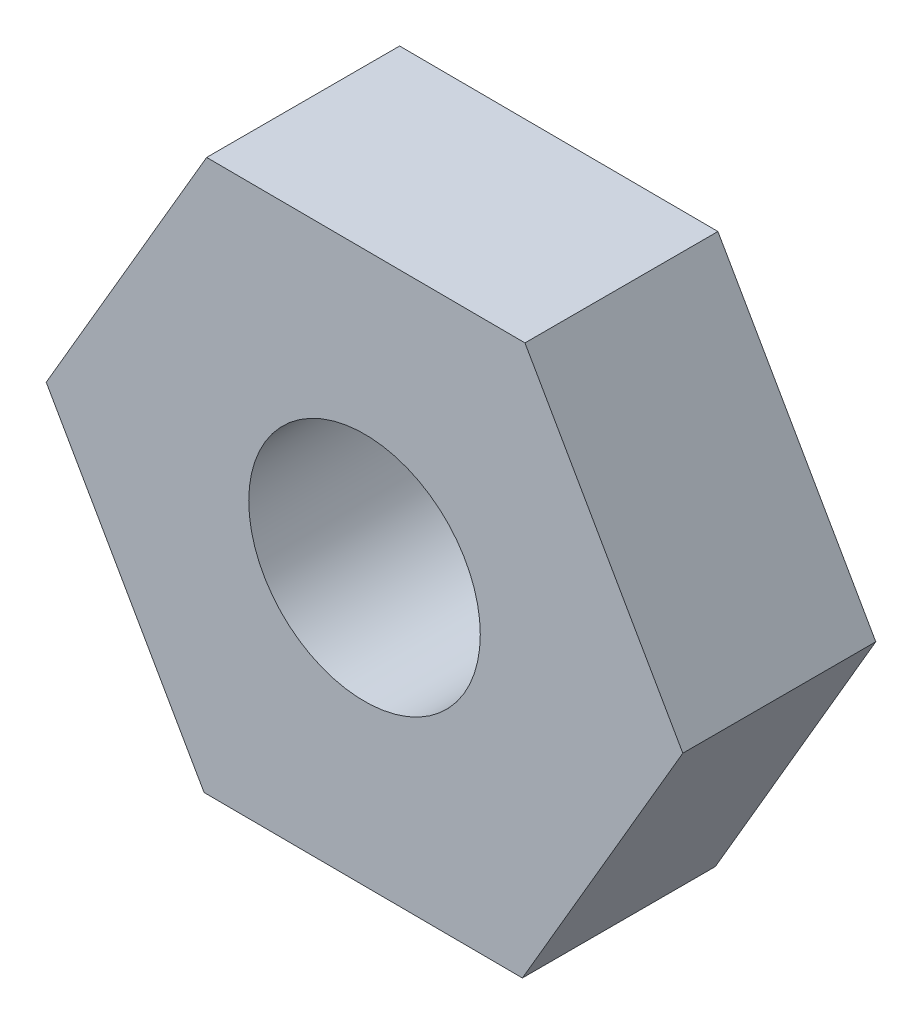
from build123d import *

# Parameters (mm, degrees)
SKETCH_1_R      = 2.1
EXTRUDE_1_DEPTH = 3.5


with BuildPart() as part:
    # 草图1 → 凸台-拉伸1 (new body)
    with BuildSketch(Plane.XY):
        Polygon((-2.863383752, 5.013418676), (-5.773439809, 0.026946269), (-2.910056058, -4.986472408), (2.863383752, -5.013418676), (5.773439809, -0.026946269), (2.910056058, 4.986472408), align=None)
        Circle(SKETCH_1_R, mode=Mode.SUBTRACT)
    extrude(amount=EXTRUDE_1_DEPTH)


solid = part.part
